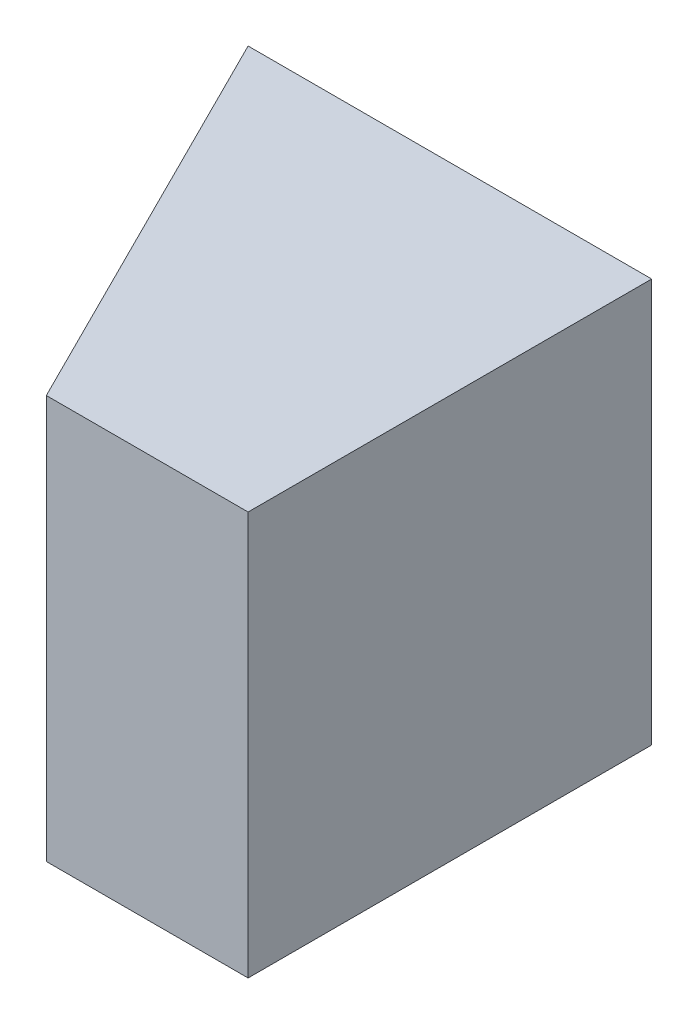
from build123d import *

# Parameters (mm, degrees)
SKETCH1_W           = 20
SKETCH1_H           = 20
BOSS_EXTRUDE1_DEPTH = 20
CUT_EXTRUDE1_DEPTH  = 20


with BuildPart() as part:
    # Sketch1 → Boss-Extrude1 (new body)
    with BuildSketch(Plane.XY):
        with Locations((10, 10)):
            Rectangle(SKETCH1_W, SKETCH1_H)
    extrude(amount=BOSS_EXTRUDE1_DEPTH)

    # Sketch2 → Cut-Extrude1 (cut)
    with BuildSketch(Plane(origin=(0, 20, 0), x_dir=(1, 0, 0), z_dir=(0, 1, 0))):
        Polygon((0, 0), (10, -20), (0, -20), align=None)
    extrude(amount=-CUT_EXTRUDE1_DEPTH, mode=Mode.SUBTRACT)


solid = part.part
